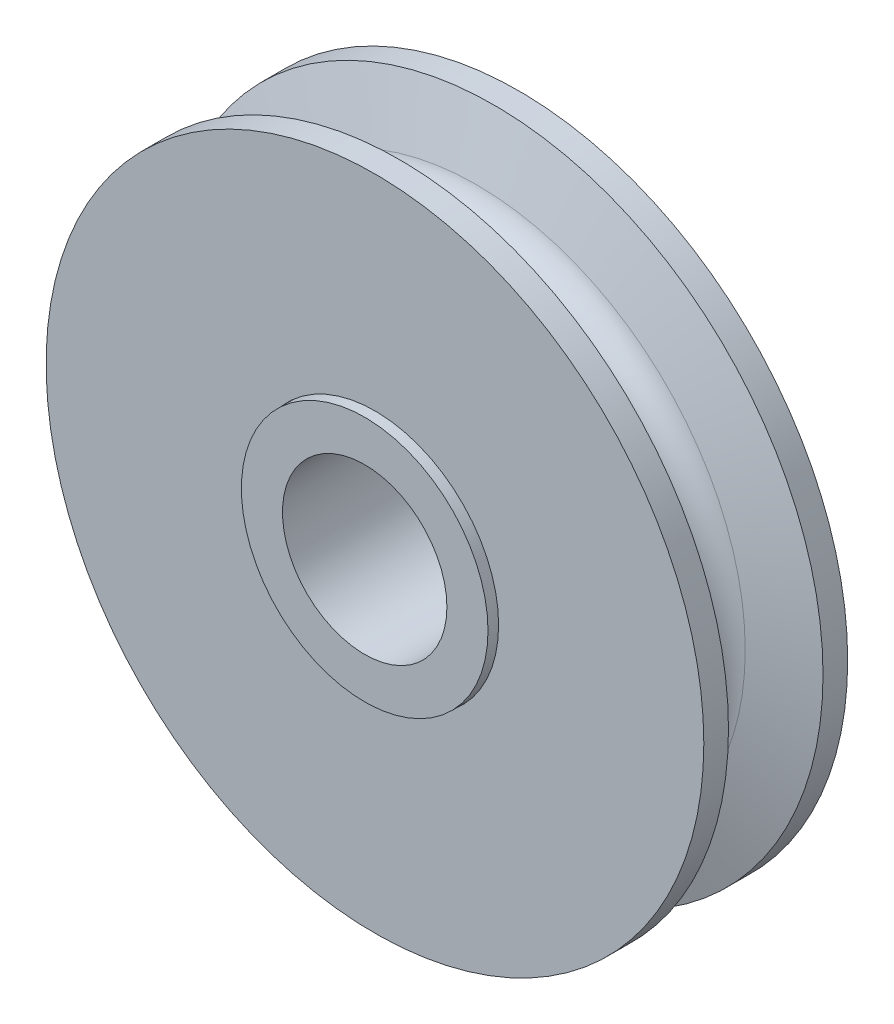
from build123d import *

# Parameters (mm, degrees)
SKETCH2_R                    = 9.5504
SKETCH2_R_2                  = 9.525
CUT_EXTRUDE_THIN1_DEPTH      = 37.477972806
CUT_EXTRUDE_THIN1_DEPTH_BACK = 37.477972806


with BuildPart() as part:
    # Sketch1 → Revolve1 (revolve)
    with BuildSketch(Plane(origin=(0, 0, 0), x_dir=(0, 0, -1), z_dir=(1, 0, 0)), mode=Mode.PRIVATE) as revolve1_sk:
        with BuildLine():
            Line((3.65125, 25.4), (5.55625, 25.4))
            Line((5.55625, 25.4), (5.55625, 9.525))
            Line((5.55625, 9.525), (6.35, 9.525))
            Line((6.35, 9.525), (6.35, 6.35))
            Line((6.35, 6.35), (-6.35, 6.35))
            Line((-6.35, 6.35), (-6.35, 9.525))
            Line((-6.35, 9.525), (-5.55625, 9.525))
            Line((-5.55625, 9.525), (-5.55625, 25.4))
            Line((-5.55625, 25.4), (-3.65125, 25.4))
            Line((-3.65125, 25.4), (-2.284240955, 20.758498321))
            ThreePointArc((-2.284240955, 20.758498321), (0, 19.05), (2.284240955, 20.758498321))
            Line((2.284240955, 20.758498321), (3.65125, 25.4))
        make_face()
    revolve(revolve1_sk.sketch.rotate(Axis((0, 0, 6.35), (0, 0, -1)), 90), axis=Axis((0, 0, 6.35), (0, 0, -1)))

    # Sketch2 → Cut-Extrude-Thin1 (cut, two sides)
    with BuildSketch(Plane.XY) as cut_extrude_thin1_sk:
        Circle(SKETCH2_R)
        Circle(SKETCH2_R_2, mode=Mode.SUBTRACT)
    extrude(amount=CUT_EXTRUDE_THIN1_DEPTH, mode=Mode.SUBTRACT)
    extrude(cut_extrude_thin1_sk.sketch, amount=-CUT_EXTRUDE_THIN1_DEPTH_BACK, mode=Mode.SUBTRACT)


with BuildPart() as cut_extrude_thin1_piece_1:
    # of the separate pieces the step leaves, piece 1, a body of its own (cut_extrude_thin1_pieces)
    add(part.part.solids().sort_by_distance((25.4, 0, -3.65125))[0])


with BuildPart() as cut_extrude_thin1_piece_2:
    # of the separate pieces the step leaves, piece 2, a body of its own (cut_extrude_thin1_pieces)
    add(part.part.solids().sort_by_distance((9.525, 0, -5.55625))[0])


solid = Compound([cut_extrude_thin1_piece_1.part, cut_extrude_thin1_piece_2.part])
